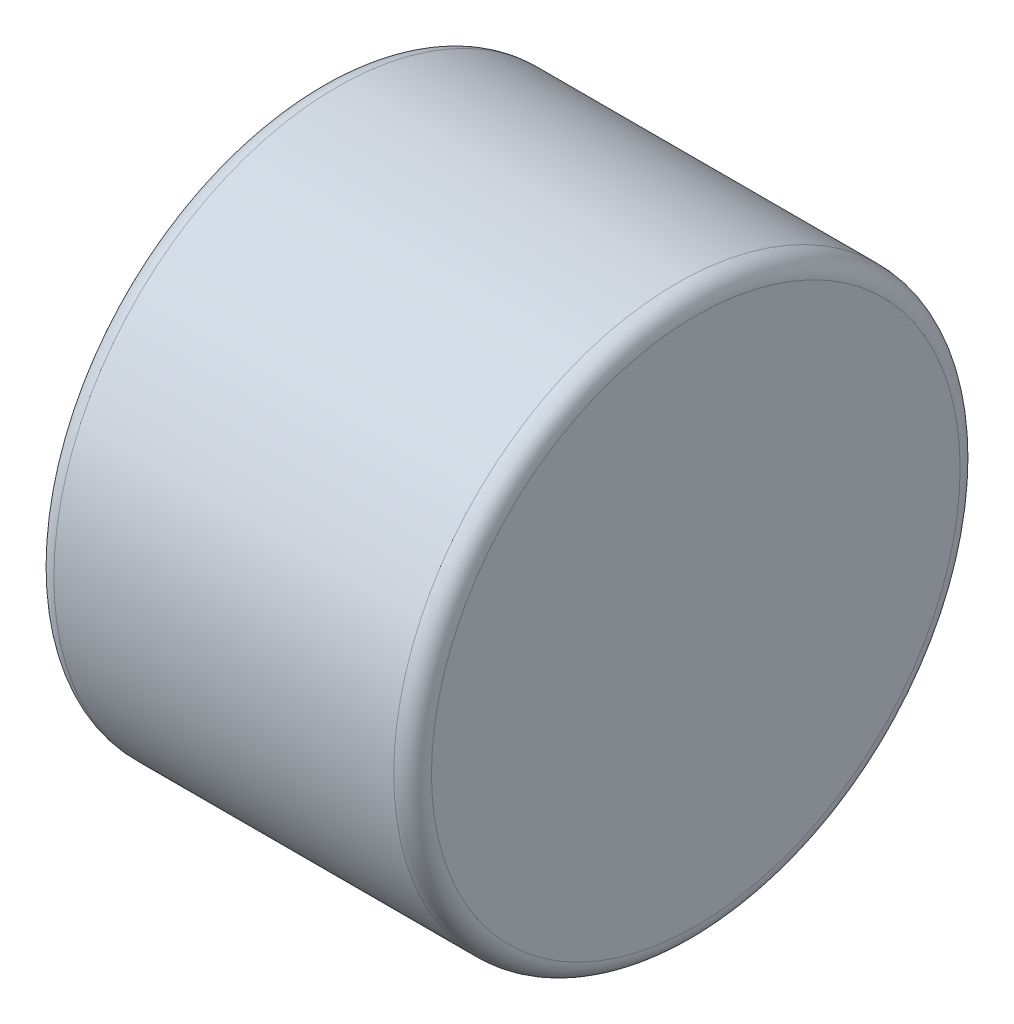
from build123d import *

# Parameters (mm, degrees)
SKETCH1_R           = 3
BOSS_EXTRUDE1_DEPTH = 2
FILLET1_R           = 0.2


with BuildPart() as part:
    # Sketch1 → Boss-Extrude1 (new body, symmetric)
    with BuildSketch(Plane(origin=(0, 0, 0), x_dir=(0, 0, -1), z_dir=(1, 0, 0))):
        Circle(SKETCH1_R)
    extrude(amount=BOSS_EXTRUDE1_DEPTH, both=True)

    # Fillet1
    fillet1_edges = [part.edges().sort_by_distance(p)[0] for p in [
        (-2, 0, 3),
        (2, 0, 3),
    ]]
    fillet(fillet1_edges, radius=FILLET1_R)


solid = part.part
